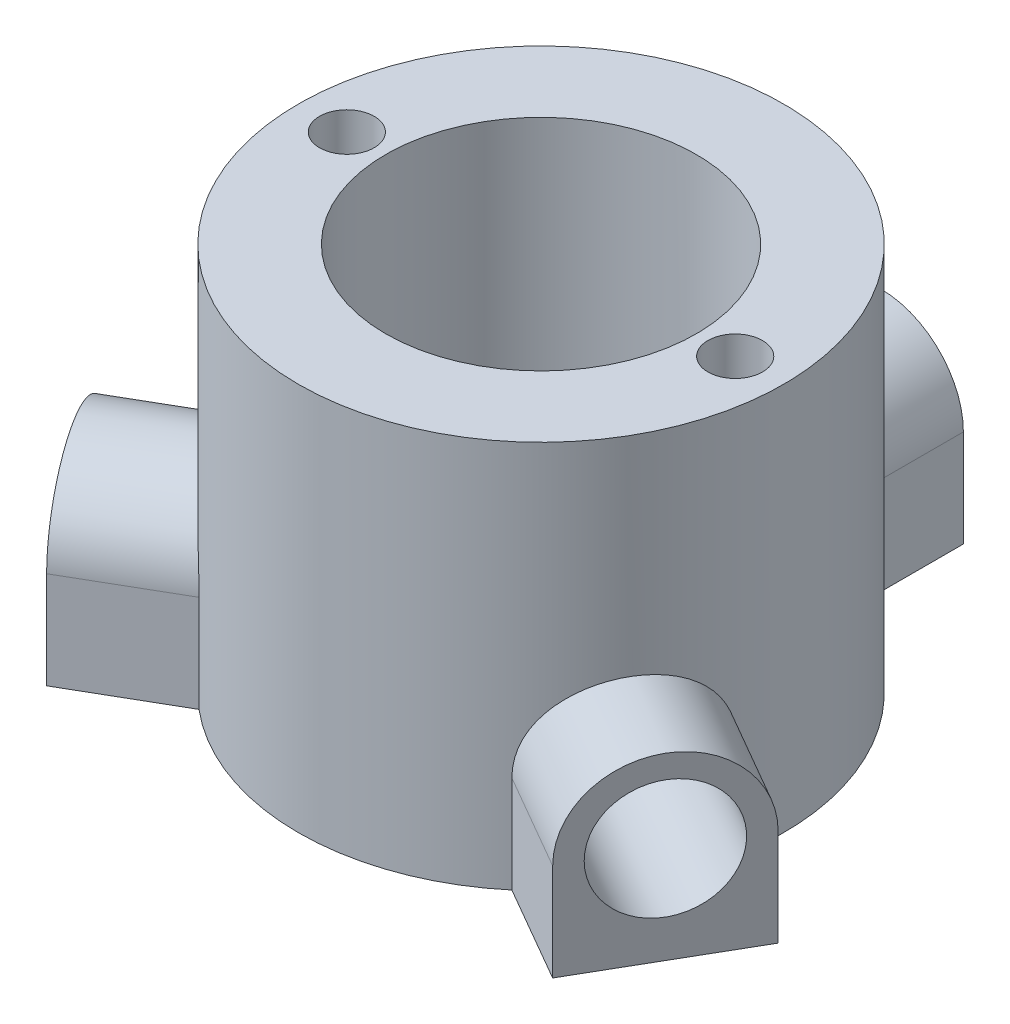
from build123d import *

# Parameters (mm, degrees)
SKETCH1_R               = 31.75
SKETCH1_R_2             = 20.32
BOSS_EXTRUDE1_DEPTH     = 50.8
BOSS_EXTRUDE2_START     = -12.7
SKETCH2_R               = 7.77875
BOSS_EXTRUDE2_DEPTH     = 14.591493
SKETCH2_2_R             = 7.77875
CUT_EXTRUDE1_DEPTH      = 12.977852
CIRPATTERN1_COUNT       = 3
F_1_4_CLEARANCE_HOLE1_D = 7.14248


with BuildPart() as part:
    # Sketch1 → Boss-Extrude1 (new body)
    with BuildSketch(Plane(origin=(0, 0, 0), x_dir=(1, 0, 0), z_dir=(0, 1, 0))):
        Circle(SKETCH1_R)
        Circle(SKETCH1_R_2, mode=Mode.SUBTRACT)
    extrude(amount=BOSS_EXTRUDE1_DEPTH)

    # Sketch2 → Boss-Extrude2 (add)
    with BuildSketch(Plane.XY.offset(-31.75).offset(BOSS_EXTRUDE2_START)):
        with BuildLine():
            Line((10.795, 12.7), (10.795, 0))
            Line((10.795, 0), (-10.795, 0))
            Line((-10.795, 0), (-10.795, 12.7))
            ThreePointArc((-10.795, 12.7), (0, 23.495), (10.795, 12.7))
        make_face()
        with Locations((0, 12.7)):
            Circle(SKETCH2_R, mode=Mode.SUBTRACT)
    boss_extrude2 = extrude(amount=BOSS_EXTRUDE2_DEPTH)

    # Sketch2_2 → Cut-Extrude1 (cut)
    with BuildSketch(Plane.XY.offset(-31.75)):
        with Locations((0, 12.7)):
            Circle(SKETCH2_2_R)
    cut_extrude1 = extrude(amount=CUT_EXTRUDE1_DEPTH, mode=Mode.SUBTRACT)

    # CirPattern1: Boss-Extrude2, Cut-Extrude1 ×3 about axis
    cirpattern1_axis = Axis((0, 0, 0), (0, 1, 0))
    for i in range(1, CIRPATTERN1_COUNT):
        add(boss_extrude2.rotate(cirpattern1_axis, i * 360 / CIRPATTERN1_COUNT))
        add(cut_extrude1.rotate(cirpattern1_axis, i * 360 / CIRPATTERN1_COUNT), mode=Mode.SUBTRACT)

    # 1_4 Clearance Hole1 (through all)
    with Locations(Plane(origin=(0, 50.8, 0), x_dir=(1, 0, 0), z_dir=(0, 1, 0))):
        with Locations((-25.4, 0), (25.4, 0)):
            Hole(F_1_4_CLEARANCE_HOLE1_D / 2)


solid = part.part
